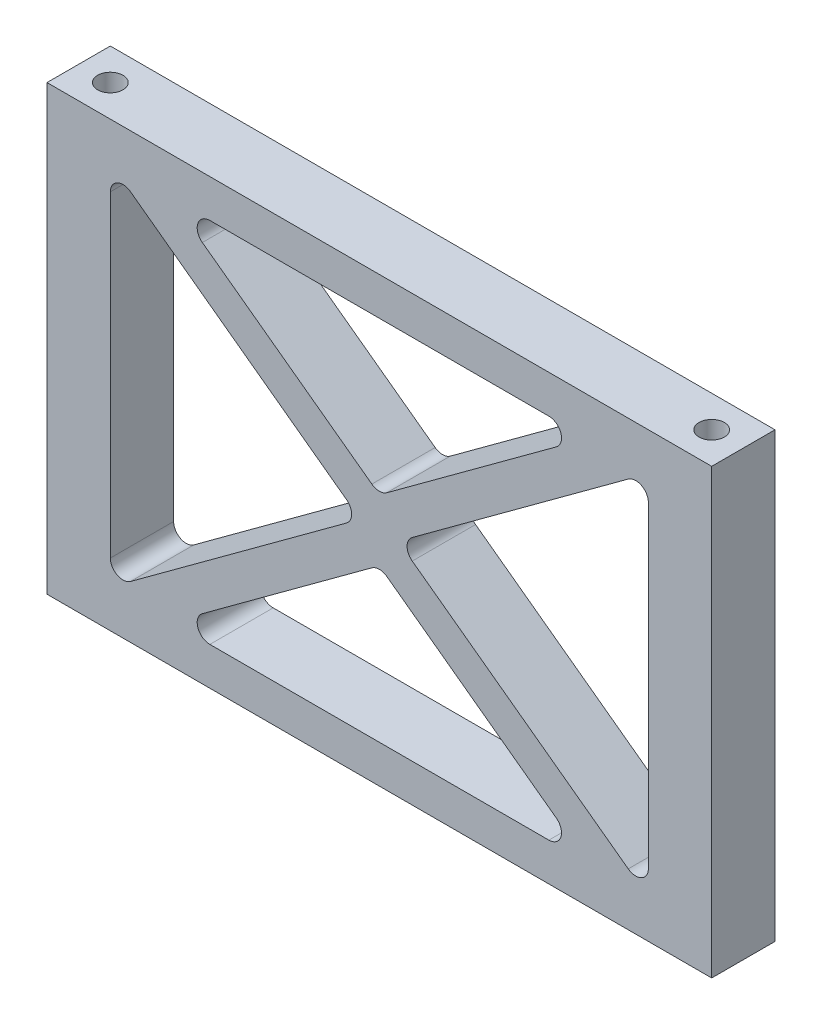
from build123d import *

# Parameters (mm, degrees)
SKIZZE1_W                       = 105
SKIZZE1_H                       = 70
AUFSATZ_LINEAR_AUSTRAGEN1_DEPTH = 10
SCHNITT_LINEAR_AUSTRAGEN1_DEPTH = 10
SKIZZE3_R                       = 1.5
SCHNITT_LINEAR_AUSTRAGEN2_DEPTH = 71
SKIZZE4_R                       = 2
SCHNITT_LINEAR_AUSTRAGEN3_DEPTH = 6
SKIZZE5_R                       = 2
SCHNITT_LINEAR_AUSTRAGEN4_DEPTH = 6


with BuildPart() as part:
    # Skizze1 → Aufsatz-Linear austragen1 (new body)
    with BuildSketch(Plane.XY):
        with Locations((52.5, 35)):
            Rectangle(SKIZZE1_W, SKIZZE1_H)
    extrude(amount=AUFSATZ_LINEAR_AUSTRAGEN1_DEPTH)

    # Skizze2 → Schnitt-Linear austragen1 (cut)
    with BuildSketch(Plane.XY.offset(10)):
        with BuildLine():
            Line((10, 60.05034464), (10, 9.94965536))
            ThreePointArc((10, 9.94965536), (11.096486968, 8.165372815), (13.183664201, 8.337532828))
            Line((13.183664201, 8.337532828), (47.301638716, 33.387877468))
            ThreePointArc((47.301638716, 33.387877468), (48.117974515, 35), (47.301638716, 36.612122532))
            Line((47.301638716, 36.612122532), (13.183664201, 61.662467172))
            ThreePointArc((13.183664201, 61.662467172), (11.096486968, 61.834627185), (10, 60.05034464))
        make_face()
        with BuildLine():
            Line((51.316335799, 40.729297855), (24.54181721, 60.387877468))
            ThreePointArc((24.54181721, 60.387877468), (23.824922931, 62.622798095), (25.72548141, 64))
            Line((25.72548141, 64), (79.27451859, 64))
            ThreePointArc((79.27451859, 64), (81.175077069, 62.622798095), (80.45818279, 60.387877468))
            Line((80.45818279, 60.387877468), (53.683664201, 40.729297855))
            ThreePointArc((53.683664201, 40.729297855), (52.5, 40.341420387), (51.316335799, 40.729297855))
        make_face()
        with BuildLine():
            Line((25.72548141, 6), (79.27451859, 6))
            ThreePointArc((79.27451859, 6), (81.175077069, 7.377201905), (80.45818279, 9.612122532))
            Line((80.45818279, 9.612122532), (53.683664201, 29.270702145))
            ThreePointArc((53.683664201, 29.270702145), (52.5, 29.658579613), (51.316335799, 29.270702145))
            Line((51.316335799, 29.270702145), (24.54181721, 9.612122532))
            ThreePointArc((24.54181721, 9.612122532), (23.824922931, 7.377201905), (25.72548141, 6))
        make_face()
        with BuildLine():
            Line((95, 60.05034464), (95, 9.94965536))
            ThreePointArc((95, 9.94965536), (93.903513032, 8.165372815), (91.816335799, 8.337532828))
            Line((91.816335799, 8.337532828), (57.698361284, 33.387877468))
            ThreePointArc((57.698361284, 33.387877468), (56.882025485, 35), (57.698361284, 36.612122532))
            Line((57.698361284, 36.612122532), (91.816335799, 61.662467172))
            ThreePointArc((91.816335799, 61.662467172), (93.903513032, 61.834627185), (95, 60.05034464))
        make_face()
    extrude(amount=-SCHNITT_LINEAR_AUSTRAGEN1_DEPTH, mode=Mode.SUBTRACT)

    # Skizze3 → Schnitt-Linear austragen2 (cut, through all)
    with BuildSketch(Plane(origin=(0, 70, 0), x_dir=(1, 0, 0), z_dir=(0, 1, 0))):
        with Locations((5, -5)):
            Circle(SKIZZE3_R)
        with Locations((100, -5)):
            Circle(SKIZZE3_R)
    extrude(amount=-SCHNITT_LINEAR_AUSTRAGEN2_DEPTH, mode=Mode.SUBTRACT)

    # Skizze4 → Schnitt-Linear austragen3 (cut)
    with BuildSketch(Plane.XZ):
        with Locations((5, 5)):
            Circle(SKIZZE4_R)
        with Locations((100, 5)):
            Circle(SKIZZE4_R)
    extrude(amount=-SCHNITT_LINEAR_AUSTRAGEN3_DEPTH, mode=Mode.SUBTRACT)

    # Skizze5 → Schnitt-Linear austragen4 (cut)
    with BuildSketch(Plane(origin=(0, 70, 0), x_dir=(1, 0, 0), z_dir=(0, 1, 0))):
        with Locations((5, -5)):
            Circle(SKIZZE5_R)
        with Locations((100, -5)):
            Circle(SKIZZE5_R)
    extrude(amount=-SCHNITT_LINEAR_AUSTRAGEN4_DEPTH, mode=Mode.SUBTRACT)


solid = part.part
